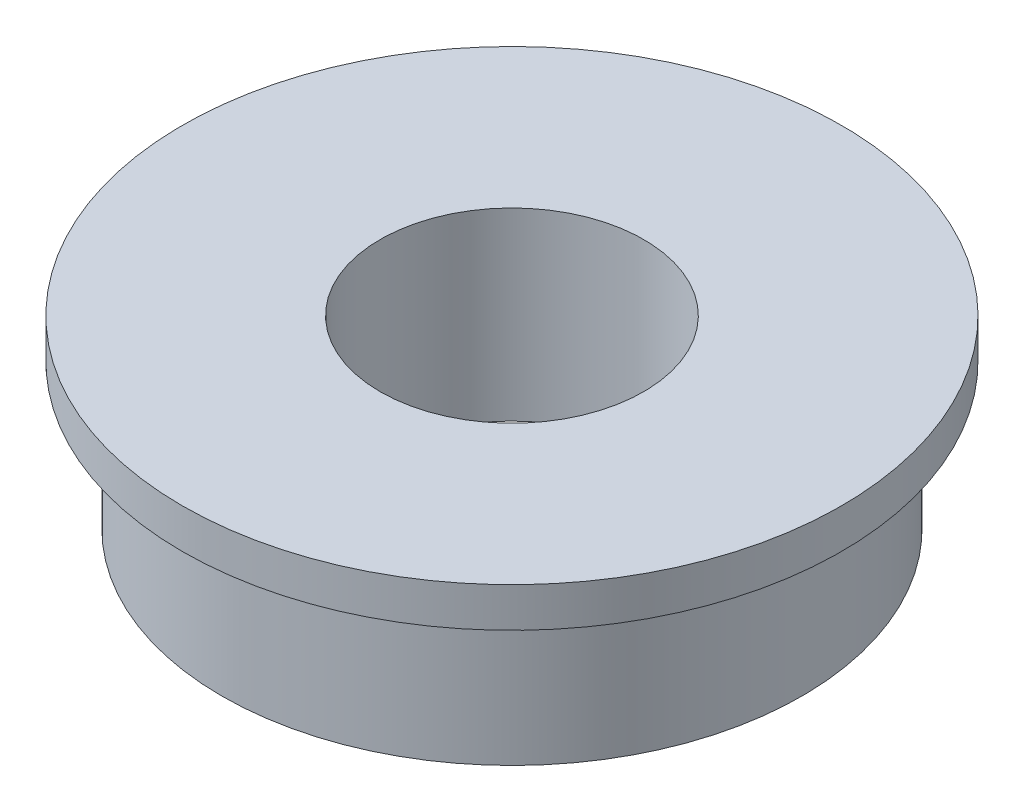
from build123d import *

# Parameters (mm, degrees)
SKETCH1_R           = 11
SKETCH1_R_2         = 5
BOSS_EXTRUDE1_DEPTH = 3.5
SKETCH2_R           = 12.5
SKETCH2_R_2         = 11
BOSS_EXTRUDE2_DEPTH = 1.5


with BuildPart() as part:
    # Sketch1 → Boss-Extrude1 (new body, symmetric)
    with BuildSketch(Plane(origin=(0, 0, 0), x_dir=(1, 0, 0), z_dir=(0, 1, 0))):
        Circle(SKETCH1_R)
        Circle(SKETCH1_R_2, mode=Mode.SUBTRACT)
    extrude(amount=BOSS_EXTRUDE1_DEPTH, both=True)

    # Sketch2 → Boss-Extrude2 (add)
    with BuildSketch(Plane(origin=(0, 3.5, 0), x_dir=(1, 0, 0), z_dir=(0, 1, 0))):
        Circle(SKETCH2_R)
        Circle(SKETCH2_R_2, mode=Mode.SUBTRACT)
    extrude(amount=-BOSS_EXTRUDE2_DEPTH)


solid = part.part
